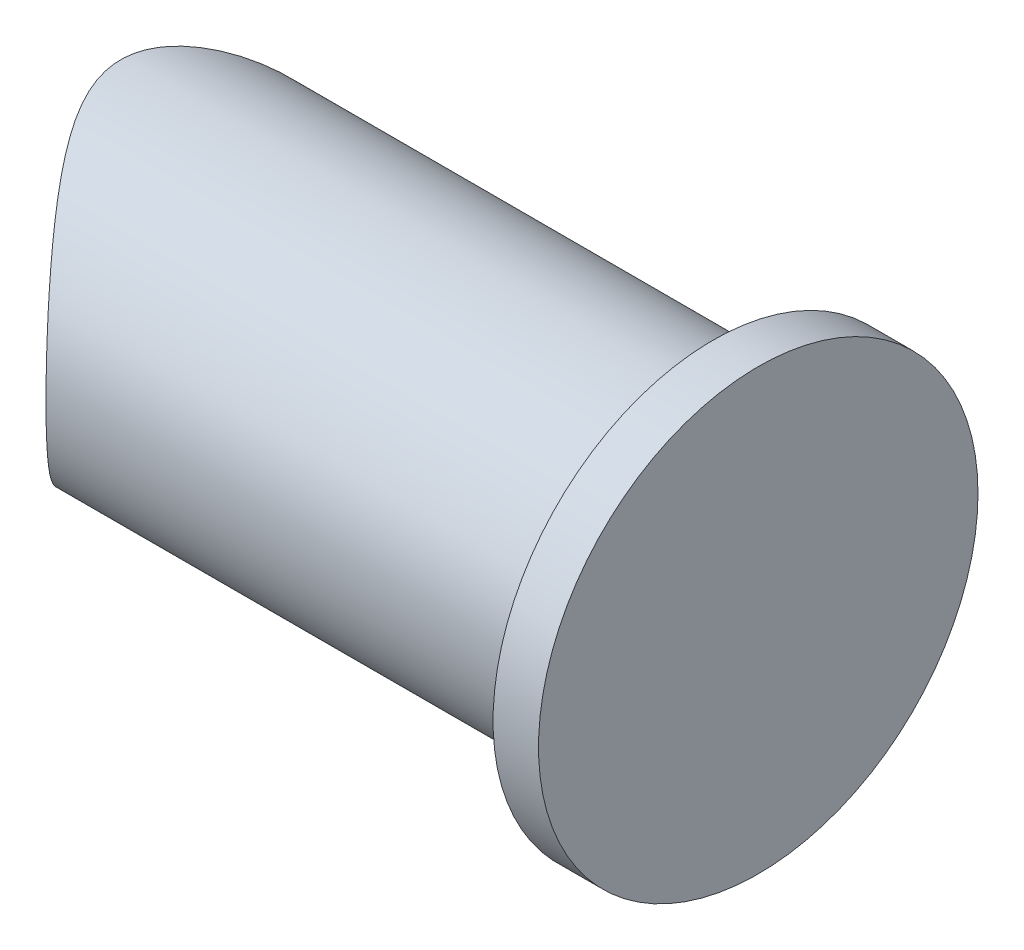
from build123d import *

# Parameters (mm, degrees)
ESBO_O1_R             = 11
EXTRUS_O1_DEPTH       = 50
ESBO_O2_R             = 13
CORTE_EXTRUS_O1_DEPTH = 40
ESBO_O3_R             = 14.5
EXTRUS_O2_DEPTH       = 3


with BuildPart() as part:
    # Esboço1 → Extrusão1 (new body)
    with BuildSketch(Plane(origin=(0, 0, 0), x_dir=(0, 0, -1), z_dir=(1, 0, 0))):
        Circle(ESBO_O1_R)
    extrude(amount=-EXTRUS_O1_DEPTH)

    # Esboço2 → Corte-extrusão1 (cut, symmetric)
    with BuildSketch(Plane.XY):
        with Locations((-46, 0)):
            Circle(ESBO_O2_R)
    extrude(amount=CORTE_EXTRUS_O1_DEPTH, both=True, mode=Mode.SUBTRACT)

    # Esboço3 → Extrusão2 (add)
    with BuildSketch(Plane(origin=(0, 0, 0), x_dir=(0, 0, -1), z_dir=(1, 0, 0))):
        Circle(ESBO_O3_R)
    extrude(amount=EXTRUS_O2_DEPTH)


solid = part.part
